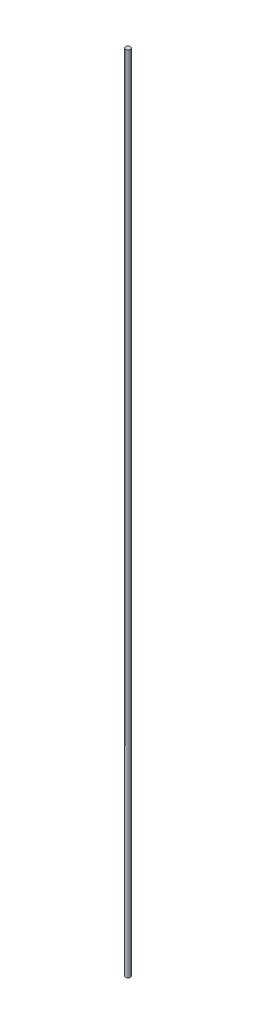
from build123d import *

# Parameters (mm, degrees)
SKETCH1_R           = 3
BOSS_EXTRUDE1_DEPTH = 1000


with BuildPart() as part:
    # Sketch1 → Boss-Extrude1 (new body)
    with BuildSketch(Plane(origin=(0, 0, 0), x_dir=(1, 0, 0), z_dir=(0, 1, 0))):
        Circle(SKETCH1_R)
    extrude(amount=BOSS_EXTRUDE1_DEPTH)


solid = part.part
